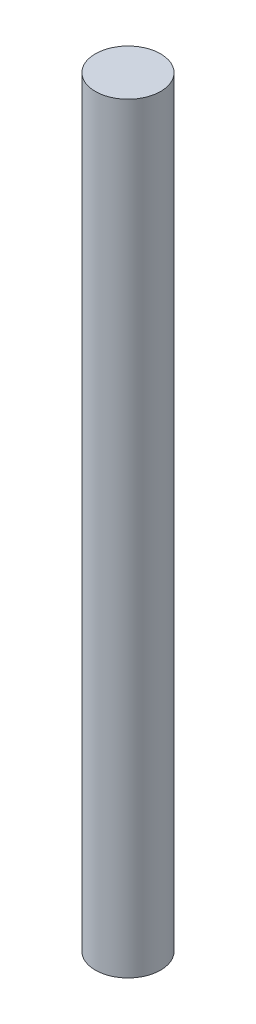
from build123d import *

# Parameters (mm, degrees)
ESQUISSE1_R      = 1.5
EXTRUSION1_DEPTH = 35


with BuildPart() as part:
    # Esquisse1 → Extrusion1 (new body)
    with BuildSketch(Plane(origin=(0, 0, 0), x_dir=(1, 0, 0), z_dir=(0, 1, 0))):
        Circle(ESQUISSE1_R)
    extrude(amount=EXTRUSION1_DEPTH)


solid = part.part
